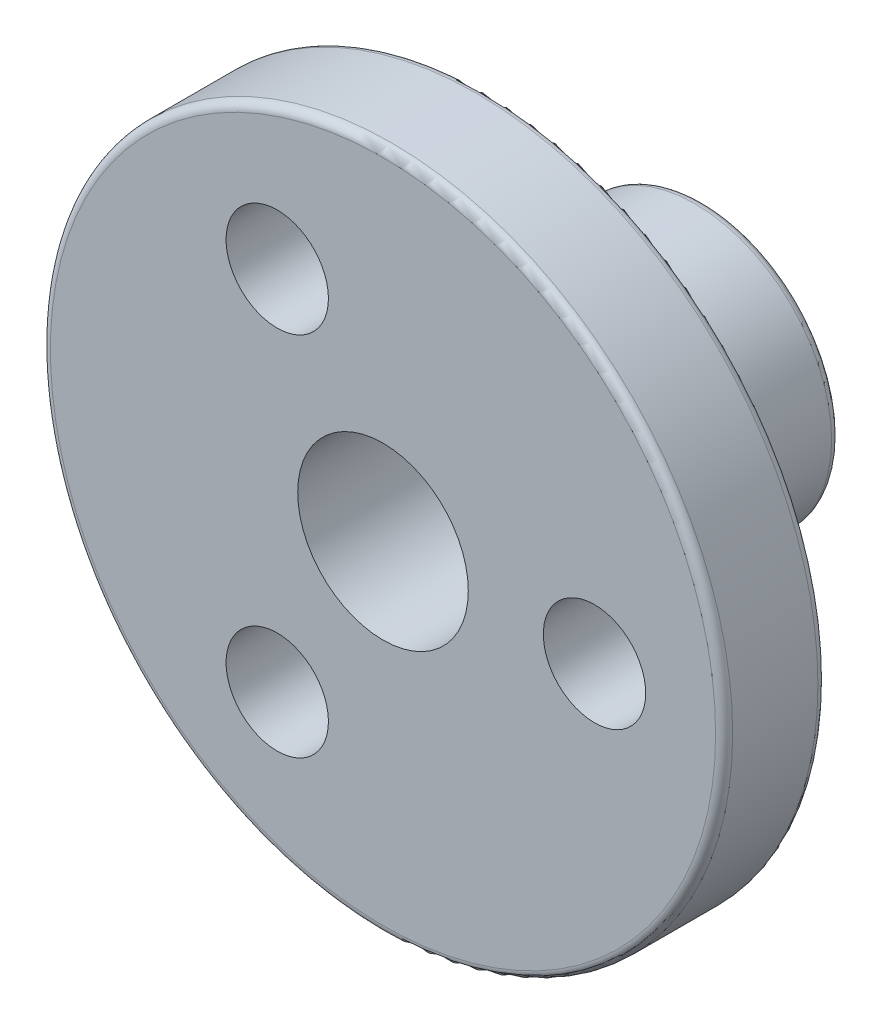
from build123d import *

# Parameters (mm, degrees)
SKETCH1_R           = 10
SKETCH1_R_2         = 2.5
SKETCH1_R_3         = 1.5
BOSS_EXTRUDE1_DEPTH = 3
SKETCH2_R           = 4
SKETCH2_R_2         = 2.5
BOSS_EXTRUDE2_DEPTH = 6.4
FILLET1_R           = 0.25
FILLET2_R           = 0.25
FILLET3_R           = 0.25


with BuildPart() as part:
    # Sketch1 → Boss-Extrude1 (new body)
    with BuildSketch(Plane.XY):
        Circle(SKETCH1_R)
        Circle(SKETCH1_R_2, mode=Mode.SUBTRACT)
        with Locations((6.2, 0)):
            Circle(SKETCH1_R_3, mode=Mode.SUBTRACT)
        with Locations((-3.1, -5.369357503)):
            Circle(SKETCH1_R_3, mode=Mode.SUBTRACT)
        with Locations((-3.1, 5.369357503)):
            Circle(SKETCH1_R_3, mode=Mode.SUBTRACT)
    extrude(amount=BOSS_EXTRUDE1_DEPTH)

    # Sketch2 → Boss-Extrude2 (add)
    with BuildSketch(Plane(origin=(0, 0, 0), x_dir=(-1, 0, 0), z_dir=(0, 0, -1))):
        Circle(SKETCH2_R)
        Circle(SKETCH2_R_2, mode=Mode.SUBTRACT)
    extrude(amount=BOSS_EXTRUDE2_DEPTH)

    # Fillet1
    fillet1_edges = [part.edges().sort_by_distance(p)[0] for p in [
        (4, 0, 0),
    ]]
    fillet(fillet1_edges, radius=FILLET1_R)

    # Fillet2
    fillet2_edges = [part.edges().sort_by_distance(p)[0] for p in [
        (4, 0, -6.4),
    ]]
    fillet(fillet2_edges, radius=FILLET2_R)

    # Fillet3
    fillet3_edges = [part.edges().sort_by_distance(p)[0] for p in [
        (-10, 0, 0),
        (-10, 0, 3),
    ]]
    fillet(fillet3_edges, radius=FILLET3_R)


solid = part.part
